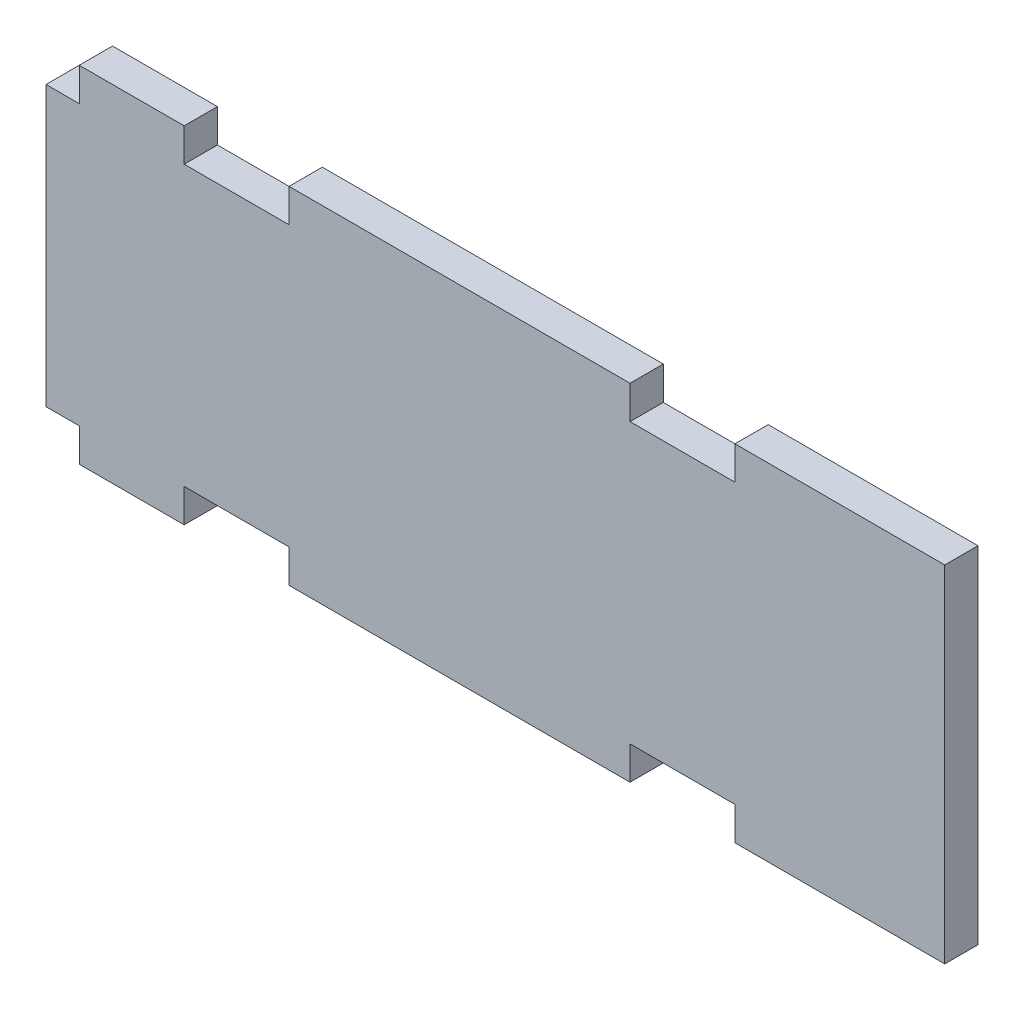
from build123d import *

# Parameters (mm, degrees)
BOSS_EXTRUDE1_DEPTH = 3.17


with BuildPart() as part:
    # Sketch1 → Boss-Extrude1 (new body)
    with BuildSketch(Plane.XY):
        Polygon((55.67, -3.17), (55.67, 0), (23.17, 0), (23.17, -3.17), (13.17, -3.17), (13.17, 0), (3.17, 0), (3.17, -3.17), (0, -3.17), (0, -29.77), (3.17, -29.77), (3.17, -32.94), (13.17, -32.94), (13.17, -29.77), (23.17, -29.77), (23.17, -32.94), (55.67, -32.94), (55.67, -29.77), (65.67, -29.77), (65.67, -32.94), (85.67, -32.94), (85.67, 0), (65.67, 0), (65.67, -3.17), align=None)
    extrude(amount=BOSS_EXTRUDE1_DEPTH)


solid = part.part
